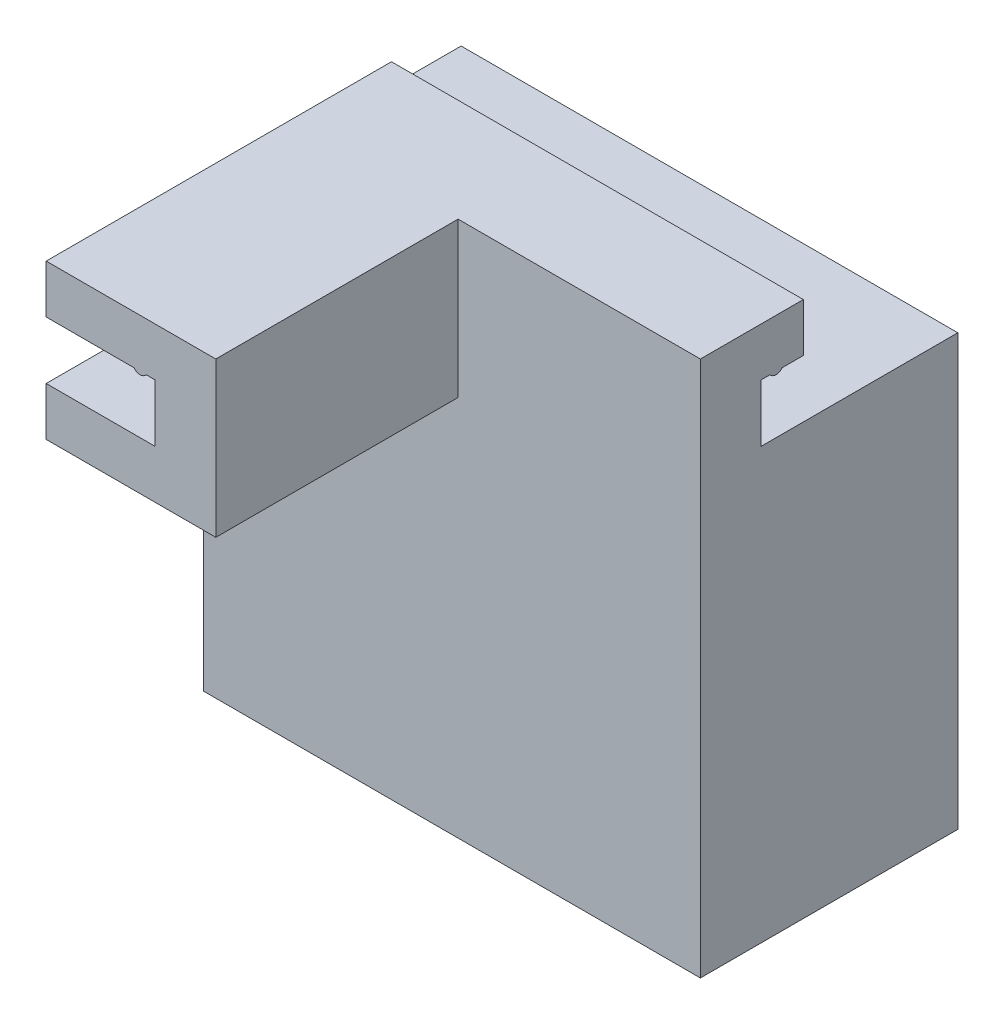
from build123d import *

# Parameters (mm, degrees)
BOSS_EXTRUDE1_DEPTH = 50
SKETCH2_W           = 7
SKETCH2_H           = 8
BOSS_EXTRUDE2_DEPTH = 50
SKETCH2_3_W         = 7
SKETCH2_3_H         = 8
BOSS_EXTRUDE3_DEPTH = 18
SKETCH3_W           = 10
SKETCH3_H           = 63
SKETCH3_W_2         = 7
SKETCH3_H_2         = 8
BOSS_EXTRUDE4_DEPTH = 82


with BuildPart() as part:
    # Sketch1 → Boss-Extrude1 (new body)
    with BuildSketch(Plane.XY):
        with BuildLine():
            Line((-1.5, -8), (-3.5, -8))
            ThreePointArc((-3.5, -8), (-2.5, -8.5), (-1.5, -8))
        make_face()
        Polygon((10, -25.5), (10, 0), (0, 0), (-18, 0), (-18, -8), (0, -8), (0, -17.5), (-18, -17.5), (-18, -25.5), align=None)
    extrude(amount=BOSS_EXTRUDE1_DEPTH)

    # Sketch2 → Boss-Extrude2 (add)
    with BuildSketch(Plane(origin=(0, 0, 0), x_dir=(0, 0, -1), z_dir=(1, 0, 0))):
        Polygon((7, 0), (0, 0), (0, -8), (1.5, -8), (3.5, -8), (7, -8), align=None)
        Polygon((0, -8), (0, 0), (-10, 0), (-10, -25.5), (0, -25.5), (0, -17.5), align=None)
        with Locations((3.5, -21.5)):
            Rectangle(SKETCH2_W, SKETCH2_H)
        with BuildLine():
            Line((3.5, -8), (1.5, -8))
            ThreePointArc((1.5, -8), (2.5, -8.5), (3.5, -8))
        make_face()
    extrude(amount=BOSS_EXTRUDE2_DEPTH)

    # Sketch2_3 → Boss-Extrude3 (add)
    with BuildSketch(Plane(origin=(0, 0, 0), x_dir=(0, 0, -1), z_dir=(1, 0, 0))):
        Polygon((7, 0), (0, 0), (0, -8), (1.5, -8), (3.5, -8), (7, -8), align=None)
        with Locations((3.5, -21.5)):
            Rectangle(SKETCH2_3_W, SKETCH2_3_H)
    extrude(amount=-BOSS_EXTRUDE3_DEPTH)

    # Sketch3 → Boss-Extrude4 (add)
    with BuildSketch(Plane(origin=(50, 0, 0), x_dir=(0, 0, -1), z_dir=(1, 0, 0))):
        Polygon((32.5, -17.5), (7, -17.5), (7, -25.5), (0, -25.5), (0, -88.5), (32.5, -88.5), align=None)
        with Locations((-5, -57)):
            Rectangle(SKETCH3_W, SKETCH3_H)
        with Locations((3.5, -21.5)):
            Rectangle(SKETCH3_W_2, SKETCH3_H_2)
        with Locations((-5, -21.5)):
            Rectangle(SKETCH3_W, SKETCH3_H_2)
    extrude(amount=-BOSS_EXTRUDE4_DEPTH)


solid = part.part
